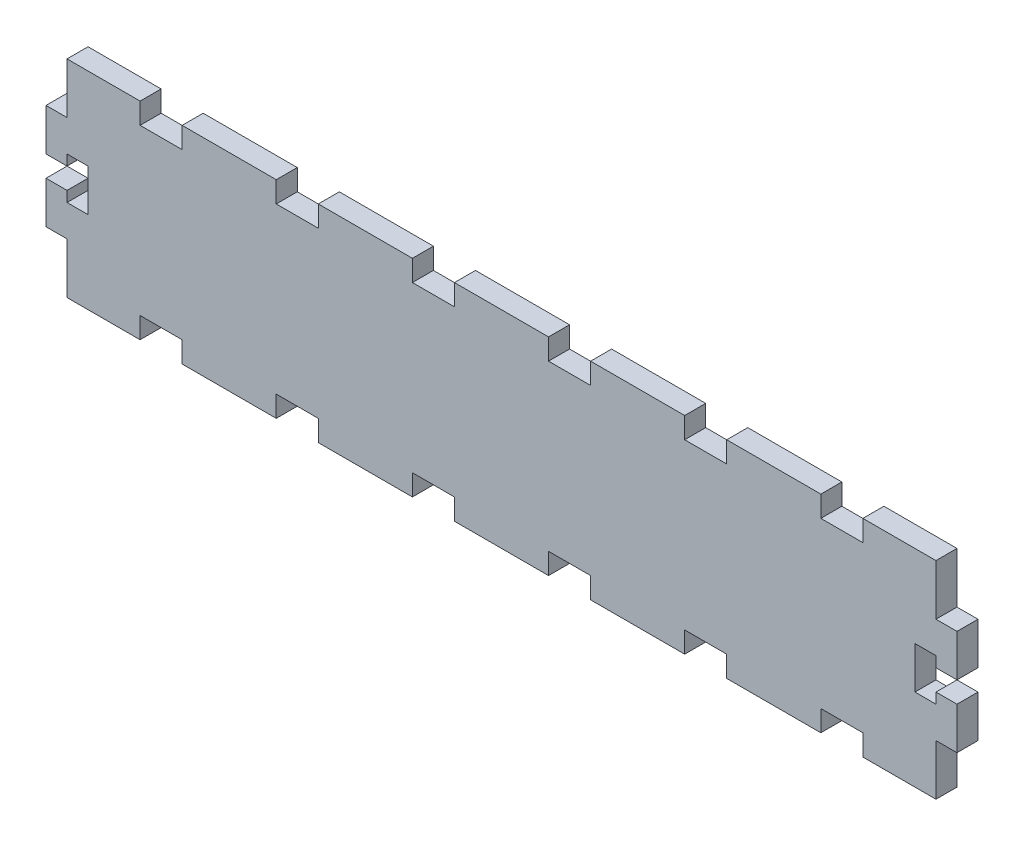
from build123d import *

# Parameters (mm, degrees)
SKETCH1_W                                  = 260
SKETCH1_H                                  = 59
BOSS_EXTRUDE1_DEPTH                        = 6
SKETCH3_W                                  = 6
SKETCH3_H                                  = 6
SKETCH3_H_2                                = 14.5
CUT_EXTRUDE1_DEPTH                         = 7
SKETCH3_3_W                                = 12
SKETCH3_3_H                                = 6
CUT_EXTRUDE2_DEPTH                         = 7
MIRROR1_AT_THE_SECOND_PLANE_COPY_1_SKETC_W = 12
MIRROR1_AT_THE_SECOND_PLANE_COPY_1_SKETC_H = 6
MIRROR1_AT_THE_SECOND_PLANE_COPY_1_DEPTH   = 7


with BuildPart() as part:
    # Sketch1 → Boss-Extrude1 (new body)
    with BuildSketch(Plane.XY):
        Rectangle(SKETCH1_W, SKETCH1_H)
    extrude(amount=-BOSS_EXTRUDE1_DEPTH)

    # Sketch3 → Cut-Extrude1 (cut, through all)
    with BuildSketch(Plane.XY):
        Polygon((-124, 6), (-124, 3), (-124, -3), (-124, -6), (-118, -6), (-118, 6), align=None)
        with Locations((-127, 0)):
            Rectangle(SKETCH3_W, SKETCH3_H)
        with Locations((-127, 22.25)):
            Rectangle(SKETCH3_W, SKETCH3_H_2)
        with Locations((-127, -22.25)):
            Rectangle(SKETCH3_W, SKETCH3_H_2)
    cut_extrude1 = extrude(amount=-CUT_EXTRUDE1_DEPTH, mode=Mode.SUBTRACT)

    # Sketch3_3 → Cut-Extrude2 (cut, through all)
    with BuildSketch(Plane.XY):
        with Locations((-97.142857143, -26.5)):
            Rectangle(SKETCH3_3_W, SKETCH3_3_H)
        with Locations((-58.285714286, -26.5)):
            Rectangle(SKETCH3_3_W, SKETCH3_3_H)
        with Locations((-19.428571429, -26.5)):
            Rectangle(SKETCH3_3_W, SKETCH3_3_H)
    cut_extrude2 = extrude(amount=-CUT_EXTRUDE2_DEPTH, mode=Mode.SUBTRACT)

    # Mirror1: Cut-Extrude2 across plane
    add(cut_extrude2.mirror(Plane(origin=(0, 0, 0), x_dir=(0, 0, 1), z_dir=(1, 0, 0))), mode=Mode.SUBTRACT)

    # Mirror1 at the second plane: Cut-Extrude2 across plane
    add(cut_extrude2.mirror(Plane.ZX), mode=Mode.SUBTRACT)

    # Mirror1 at the second plane copy 1 sketc → Mirror1 at the second plane copy 1 (cut, through all)
    with BuildSketch(Plane(origin=(0, 0, 0), x_dir=(-1, 0, 0), z_dir=(0, 0, 1))):
        with Locations((-97.142857143, -26.5)):
            Rectangle(MIRROR1_AT_THE_SECOND_PLANE_COPY_1_SKETC_W, MIRROR1_AT_THE_SECOND_PLANE_COPY_1_SKETC_H)
        with Locations((-58.285714286, -26.5)):
            Rectangle(MIRROR1_AT_THE_SECOND_PLANE_COPY_1_SKETC_W, MIRROR1_AT_THE_SECOND_PLANE_COPY_1_SKETC_H)
        with Locations((-19.428571429, -26.5)):
            Rectangle(MIRROR1_AT_THE_SECOND_PLANE_COPY_1_SKETC_W, MIRROR1_AT_THE_SECOND_PLANE_COPY_1_SKETC_H)
    extrude(amount=-MIRROR1_AT_THE_SECOND_PLANE_COPY_1_DEPTH, mode=Mode.SUBTRACT)

    # Mirror2: Cut-Extrude1 across plane
    add(cut_extrude1.mirror(Plane(origin=(0, 0, 0), x_dir=(0, 0, 1), z_dir=(1, 0, 0))), mode=Mode.SUBTRACT)


solid = part.part
